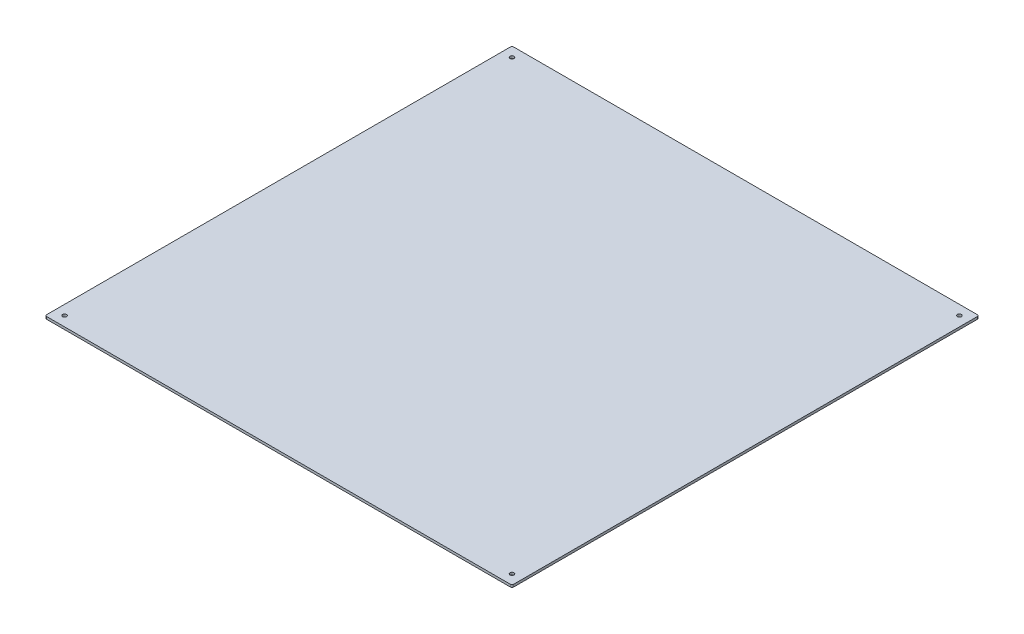
from build123d import *

# Parameters (mm, degrees)
SKETCH1_W                   = 609.6
SKETCH1_H                   = 609.6
SKETCH1_W_2                 = 609.399999892
SKETCH1_H_2                 = 609.399999892
BOSS_EXTRUDE2_DEPTH         = 3.175
F_5_0_2055_DIAMETER_HOLE1_D = 5.2197
FILLET1_R                   = 2.1082


with BuildPart() as part:
    # Sketch1 → Boss-Extrude2 (new body)
    with BuildSketch(Plane(origin=(0, 0, 0), x_dir=(1, 0, 0), z_dir=(0, 1, 0))):
        Rectangle(SKETCH1_W, SKETCH1_H)
        Rectangle(SKETCH1_W_2, SKETCH1_H_2, mode=Mode.SUBTRACT)
        Rectangle(SKETCH1_W_2, SKETCH1_H_2)
    extrude(amount=BOSS_EXTRUDE2_DEPTH)

    # #5 (0.2055) Diameter Hole1 (through all)
    with Locations(Plane(origin=(0, 0, 0), x_dir=(-1, 0, 0), z_dir=(0, -1, 0))):
        with Locations((-291.999999946, 291.999999946), (291.999999946, 291.999999946), (291.999999946, -291.999999946), (-291.999999946, -291.999999946)):
            Hole(F_5_0_2055_DIAMETER_HOLE1_D / 2)

    # Fillet1
    fillet1_edges = [part.edges().sort_by_distance(p)[0] for p in [
        (-304.8, 1.5875, -304.8),
        (304.8, 1.5875, -304.8),
        (304.8, 1.5875, 304.8),
        (-304.8, 1.5875, 304.8),
    ]]
    fillet(fillet1_edges, radius=FILLET1_R)


solid = part.part
